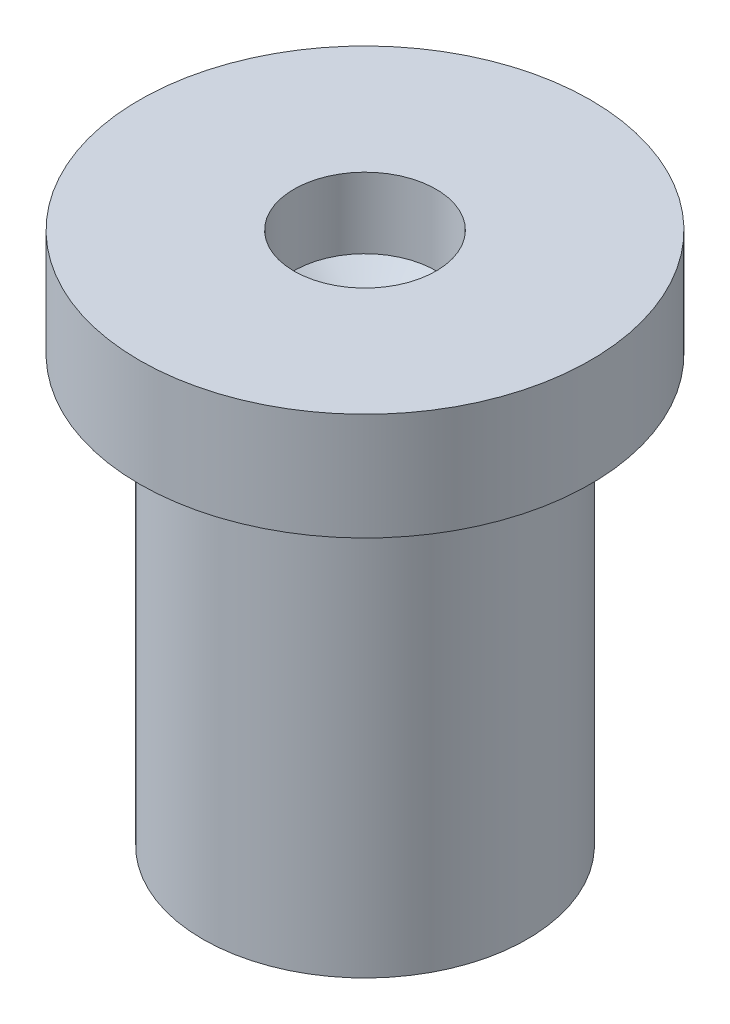
from build123d import *


with BuildPart() as part:
    # Sketch2 → Revolve1 (revolve)
    with BuildSketch(Plane.XY):
        Polygon((0, -4.693548387), (4, -4.693548387), (4, 5.806451613), (5.561605887, 5.806451613), (5.561605887, 8.449432794), (1.750970415, 8.449432794), (1.750970415, 6.707616445), (0, 5.530374348), align=None)
    revolve(axis=Axis((0, 7.048387097, 0), (0, -1, 0)))


solid = part.part
